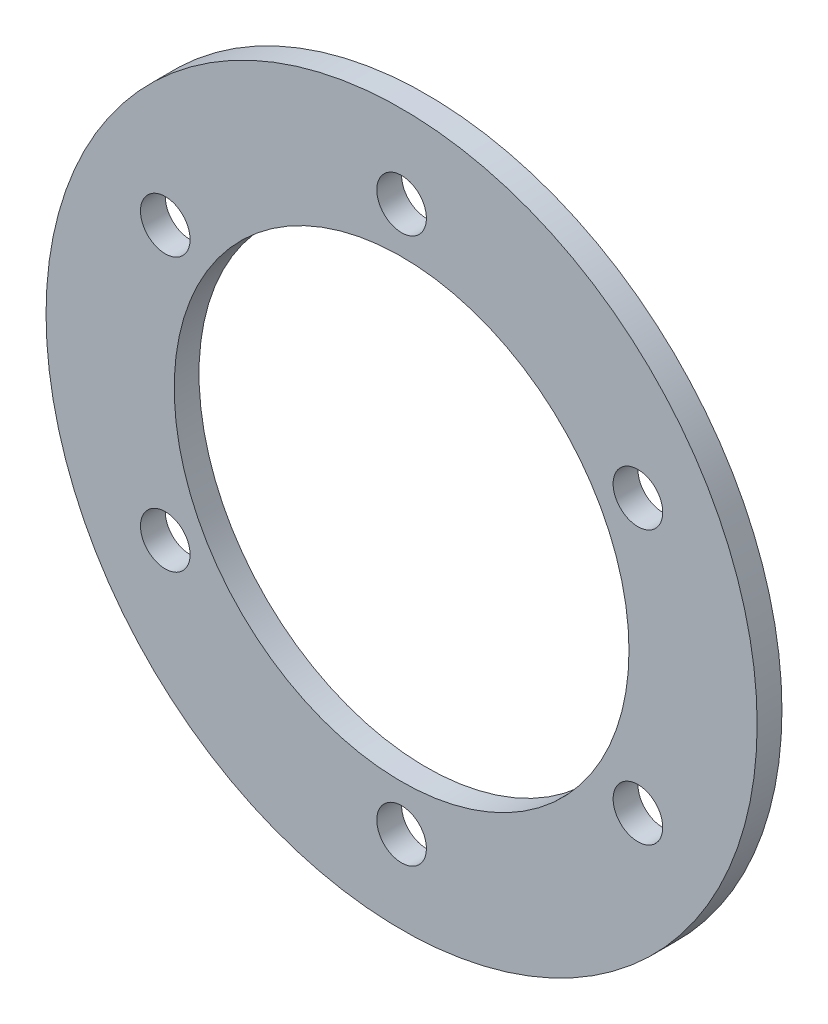
from build123d import *

# Parameters (mm, degrees)
SKETCH1_R           = 43
BOSS_EXTRUDE2_DEPTH = 3
SKETCH1_3_R         = 3
CUT_EXTRUDE1_DEPTH  = 61.88513776
CIRPATTERN2_COUNT   = 6
SKETCH1_4_R         = 27.5
CUT_EXTRUDE2_DEPTH  = 61.88513776


with BuildPart() as part:
    # Sketch1 → Boss-Extrude2 (new body)
    with BuildSketch(Plane.XY):
        Circle(SKETCH1_R)
    extrude(amount=BOSS_EXTRUDE2_DEPTH)

    # Sketch1_3 → Cut-Extrude1 (cut, through all)
    with BuildSketch(Plane.XY):
        with Locations((0, 33)):
            Circle(SKETCH1_3_R)
    cut_extrude1 = extrude(amount=CUT_EXTRUDE1_DEPTH, mode=Mode.SUBTRACT)

    # CirPattern2: Cut-Extrude1 ×6 about axis
    cirpattern2_axis = Axis((0, 0, 3), (0, 0, -1))
    for i in range(1, CIRPATTERN2_COUNT):
        add(cut_extrude1.rotate(cirpattern2_axis, i * 360 / CIRPATTERN2_COUNT), mode=Mode.SUBTRACT)

    # Sketch1_4 → Cut-Extrude2 (cut, through all)
    with BuildSketch(Plane.XY):
        Circle(SKETCH1_4_R)
    extrude(amount=CUT_EXTRUDE2_DEPTH, mode=Mode.SUBTRACT)


solid = part.part
